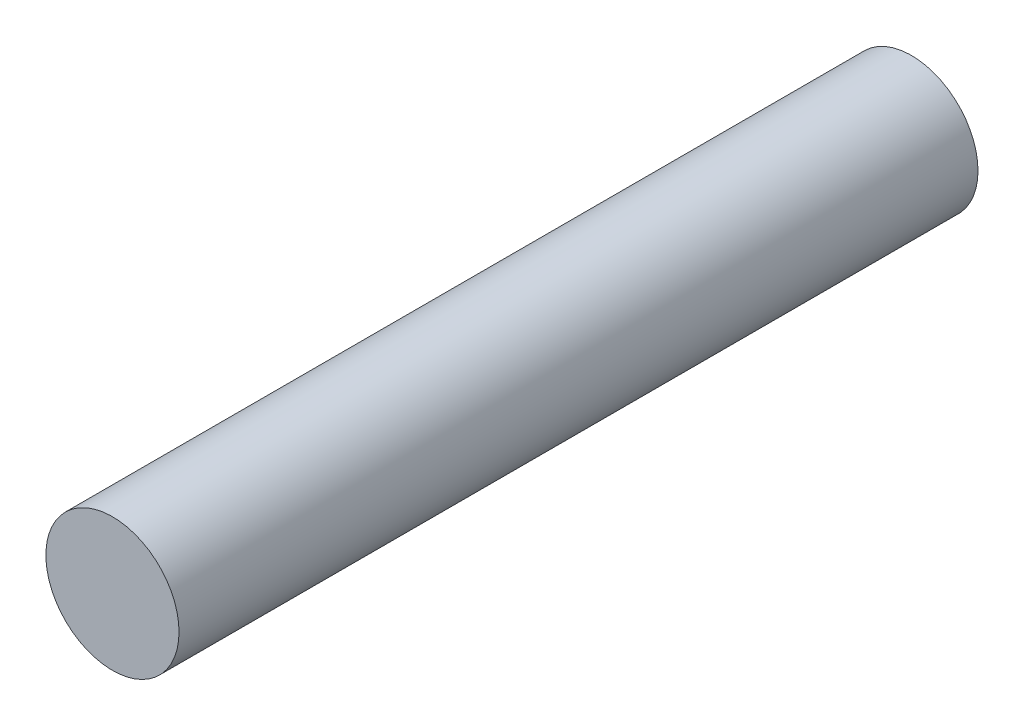
from build123d import *

# Parameters (mm, degrees)
SKETCH1_R           = 1.875
BOSS_EXTRUDE1_DEPTH = 22.5


with BuildPart() as part:
    # Sketch1 → Boss-Extrude1 (new body)
    with BuildSketch(Plane.XY):
        Circle(SKETCH1_R)
    extrude(amount=BOSS_EXTRUDE1_DEPTH)


solid = part.part
